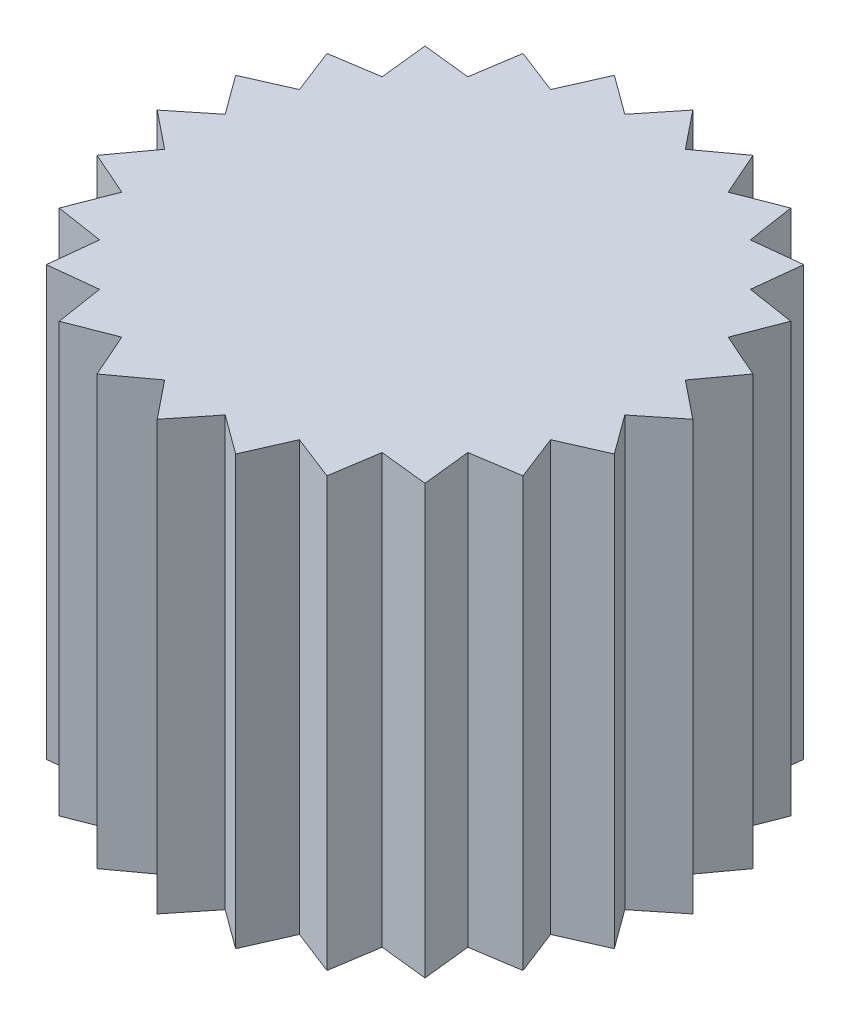
from build123d import *

# Parameters (mm, degrees)
BOSS_EXTRUDE1_DEPTH = 3


with BuildPart() as part:
    # Sketch1 → Boss-Extrude1 (new body)
    with BuildSketch(Plane(origin=(0, 0, 0), x_dir=(1, 0, 0), z_dir=(0, 1, 0))):
        Polygon((-0.212105062, 1.6110979), (0, 1.875), (0.212105062, 1.6110979), (0.48528571, 1.811110924), (0.621860578, 1.50130424), (0.9375, 1.623797632), (0.989237322, 1.289199178), (1.325825215, 1.325825215), (1.289199178, 0.989237322), (1.623797632, 0.9375), (1.50130424, 0.621860578), (1.811110924, 0.48528571), (1.6110979, 0.212105062), (1.875, 0), (1.6110979, -0.212105062), (1.811110924, -0.48528571), (1.50130424, -0.621860578), (1.623797632, -0.9375), (1.289199178, -0.989237322), (1.325825215, -1.325825215), (0.989237322, -1.289199178), (0.9375, -1.623797632), (0.621860578, -1.50130424), (0.48528571, -1.811110924), (0.212105062, -1.6110979), (0, -1.875), (-0.212105062, -1.6110979), (-0.48528571, -1.811110924), (-0.621860578, -1.50130424), (-0.9375, -1.623797632), (-0.989237322, -1.289199178), (-1.325825215, -1.325825215), (-1.289199178, -0.989237322), (-1.623797632, -0.9375), (-1.50130424, -0.621860578), (-1.811110924, -0.48528571), (-1.6110979, -0.212105062), (-1.875, 0), (-1.6110979, 0.212105062), (-1.811110924, 0.48528571), (-1.50130424, 0.621860578), (-1.623797632, 0.9375), (-1.289199178, 0.989237322), (-1.325825215, 1.325825215), (-0.989237322, 1.289199178), (-0.9375, 1.623797632), (-0.621860578, 1.50130424), (-0.48528571, 1.811110924), align=None)
    extrude(amount=-BOSS_EXTRUDE1_DEPTH)


solid = part.part
